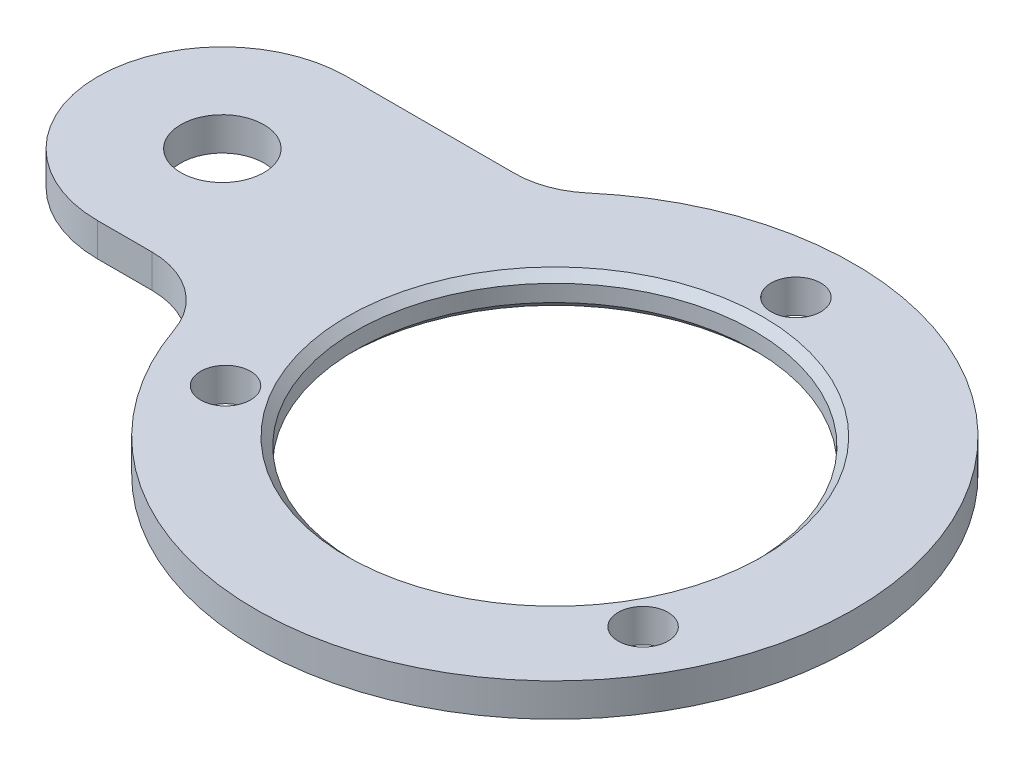
from build123d import *

# Parameters (mm, degrees)
ESQUISSE1_R      = 12
ESQUISSE1_R_2    = 1.5
ESQUISSE1_R_3    = 2.5
EXTRUSION1_DEPTH = 2
CHANFREIN1_SIZE  = 0.5


with BuildPart() as part:
    # Esquisse1 → Extrusion1 (new body)
    with BuildSketch(Plane(origin=(0, 0, 0), x_dir=(1, 0, 0), z_dir=(0, 1, 0))):
        with BuildLine():
            Line((-25, -2.5), (-21.742814905, -2.5))
            ThreePointArc((-21.742814905, -2.5), (-18.840417096, -3.428625913), (-17.016116013, -5.869565217))
            ThreePointArc((-17.016116013, -5.869565217), (17.365780251, -4.735997916), (-11.680287305, 13.695652174))
            ThreePointArc((-11.680287305, 13.695652174), (-13.19590137, 12.808425684), (-14.924811557, 12.5))
            Line((-14.924811557, 12.5), (-25, 12.5))
            ThreePointArc((-25, 12.5), (-32.5, 5), (-25, -2.5))
        make_face()
        Circle(ESQUISSE1_R, mode=Mode.SUBTRACT)
        with Locations((-12.557368355, -7.25)):
            Circle(ESQUISSE1_R_2, mode=Mode.SUBTRACT)
        with Locations((12.557368355, -7.25)):
            Circle(ESQUISSE1_R_2, mode=Mode.SUBTRACT)
        with Locations((0, 14.5)):
            Circle(ESQUISSE1_R_2, mode=Mode.SUBTRACT)
        with Locations((-25, 5)):
            Circle(ESQUISSE1_R_3, mode=Mode.SUBTRACT)
    extrude(amount=EXTRUSION1_DEPTH)

    # Chanfrein1
    chanfrein1_edges = [part.edges().sort_by_distance(p)[0] for p in [
        (-12, 0, 0),
        (-12, 2, 0),
    ]]
    chamfer(chanfrein1_edges, length=CHANFREIN1_SIZE)


solid = part.part
